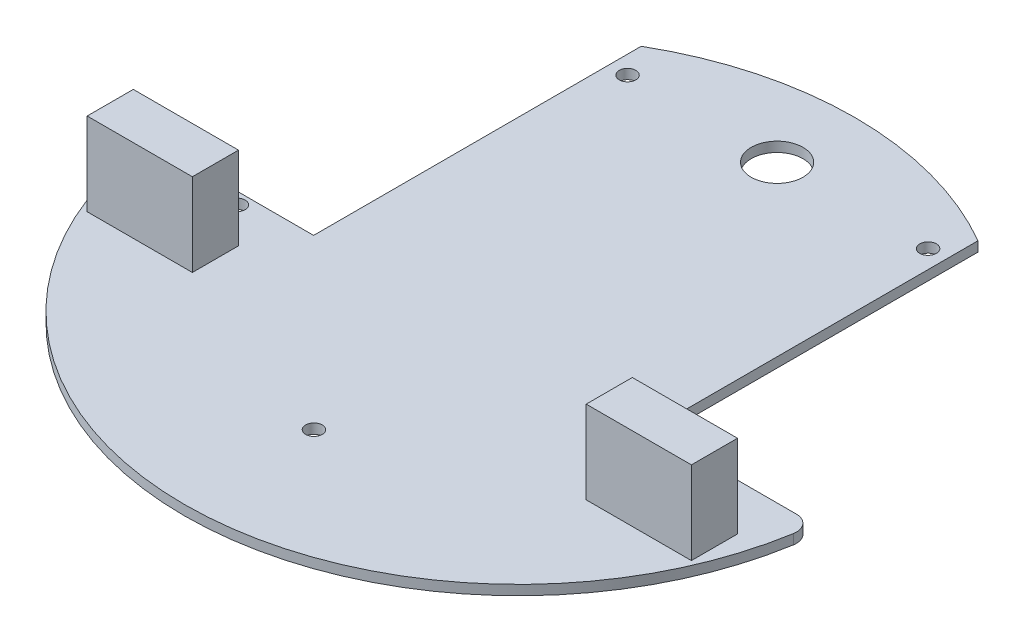
from build123d import *

# Parameters (mm, degrees)
SKETCH1_W           = 36
SKETCH1_H           = 20
BOSS_EXTRUDE1_DEPTH = 1.9
BOSS_EXTRUDE2_DEPTH = 1.9
CUT_EXTRUDE1_DEPTH  = 10
SKETCH5_R           = 5
CUT_EXTRUDE2_DEPTH  = 1.9
SKETCH6_R           = 1.6
CUT_EXTRUDE3_DEPTH  = 1.9
ESQUISSE1_W         = 20.3
ESQUISSE1_H         = 8.9
BOSS_EXTRU_1_DEPTH  = 16


with BuildPart() as part:
    # Sketch1 → Boss-Extrude1 (new body)
    with BuildSketch(Plane(origin=(0, 0, 0), x_dir=(1, 0, 0), z_dir=(0, 1, 0))):
        Rectangle(SKETCH1_W, SKETCH1_H)
    extrude(amount=BOSS_EXTRUDE1_DEPTH)

    # Sketch3 → Boss-Extrude2 (add)
    with BuildSketch(Plane.XZ):
        with BuildLine():
            Line((37.5, -26.725181376), (32.5, -26.725181376))
            Line((32.5, -26.725181376), (32.5, 33.274818624))
            Line((32.5, 33.274818624), (60.67226545, 33.274818624))
            ThreePointArc((60.67226545, 33.274818624), (62.960456011, 34.334668125), (63.631888155, 36.765362653))
            ThreePointArc((63.631888155, 36.765362653), (0, 90.718666019), (-63.631888155, 36.765362653))
            ThreePointArc((-63.631888155, 36.765362653), (-62.960456011, 34.334668125), (-60.67226545, 33.274818624))
            Line((-60.67226545, 33.274818624), (-32.5, 33.274818624))
            Line((-32.5, 33.274818624), (-32.5, -26.725181376))
            Line((-32.5, -26.725181376), (-37.5, -26.725181376))
            ThreePointArc((-37.5, -26.725181376), (0, -38.660459877), (37.5, -26.725181376))
        make_face()
    extrude(amount=-BOSS_EXTRUDE2_DEPTH)

    # Sketch4 → Cut-Extrude1 (cut)
    with BuildSketch(Plane(origin=(0, 1.9, 0), x_dir=(1, 0, 0), z_dir=(0, 1, 0))):
        Polygon((-32.5, 26.725181376), (-32.5, 34.194748576), (-40.442086395, 34.194748576), (-37.5, 26.725181376), align=None)
        Polygon((37.5, 26.725181376), (32.5, 26.725181376), (32.5, 34.194748576), (40.442086395, 34.194748576), align=None)
    extrude(amount=-CUT_EXTRUDE1_DEPTH, mode=Mode.SUBTRACT)

    # Sketch5 → Cut-Extrude2 (cut)
    with BuildSketch(Plane(origin=(0, 1.9, 0), x_dir=(1, 0, 0), z_dir=(0, 1, 0))):
        with Locations((0, 23.660459877)):
            Circle(SKETCH5_R)
    extrude(amount=-CUT_EXTRUDE2_DEPTH, mode=Mode.SUBTRACT)

    # Sketch6 → Cut-Extrude3 (cut)
    with BuildSketch(Plane(origin=(0, 1.9, 0), x_dir=(1, 0, 0), z_dir=(0, 1, 0))):
        with Locations((0, -65.718666019)):
            Circle(SKETCH6_R)
        with Locations((-45, -35.574302205)):
            Circle(SKETCH6_R)
        with Locations((45, -35.574302205)):
            Circle(SKETCH6_R)
        with Locations((-29, 23.804823691)):
            Circle(SKETCH6_R)
        with Locations((29, 23.804823691)):
            Circle(SKETCH6_R)
    extrude(amount=-CUT_EXTRUDE3_DEPTH, mode=Mode.SUBTRACT)

    # Esquisse1 → Boss.-Extru.1 (add)
    with BuildSketch(Plane(origin=(0, 1.9, 0), x_dir=(1, 0, 0), z_dir=(0, 1, 0))):
        with Locations((48.15, -46.724818624)):
            Rectangle(ESQUISSE1_W, ESQUISSE1_H)
        with Locations((-48.15, -46.724818624)):
            Rectangle(ESQUISSE1_W, ESQUISSE1_H)
    extrude(amount=BOSS_EXTRU_1_DEPTH)


solid = part.part
